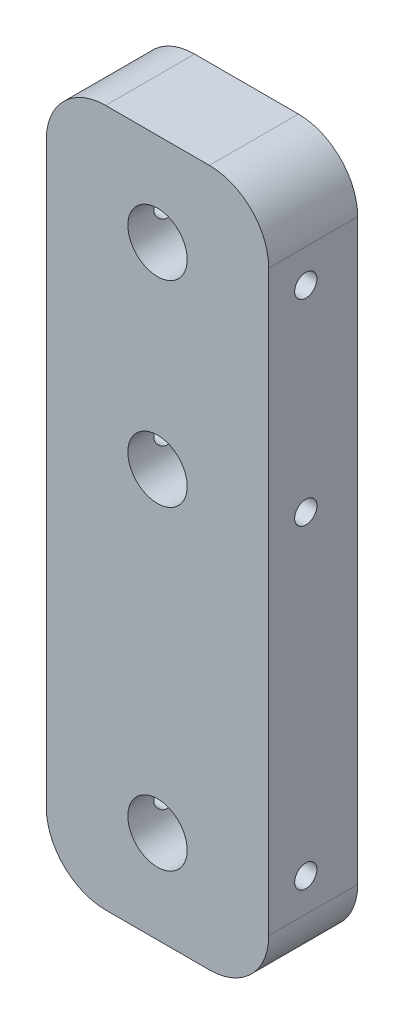
from build123d import *

# Parameters (mm, degrees)
SKETCH1_W           = 30
SKETCH1_H           = 93.98
BOSS_EXTRUDE1_DEPTH = 12
FILLET1_R           = 8
SKETCH2_R           = 4
CUT_EXTRUDE1_DEPTH  = 8
SKETCH3_R           = 1.5
CUT_EXTRUDE2_DEPTH  = 31
SKETCH4_R           = 2
CUT_EXTRUDE3_DEPTH  = 2.5


with BuildPart() as part:
    # Sketch1 → Boss-Extrude1 (new body)
    with BuildSketch(Plane.XY):
        Rectangle(SKETCH1_W, SKETCH1_H)
    extrude(amount=BOSS_EXTRUDE1_DEPTH)

    # Fillet1
    fillet1_edges = [part.edges().sort_by_distance(p)[0] for p in [
        (15, -46.99, 6),
        (-15, -46.99, 6),
        (-15, 46.99, 6),
        (15, 46.99, 6),
    ]]
    fillet(fillet1_edges, radius=FILLET1_R)

    # Sketch2 → Cut-Extrude1 (cut)
    with BuildSketch(Plane.XY.offset(12)):
        with Locations((0, 7.99)):
            Circle(SKETCH2_R)
        with Locations((0, 34.49)):
            Circle(SKETCH2_R)
        with Locations((0, -34.494880812)):
            Circle(SKETCH2_R)
    extrude(amount=-CUT_EXTRUDE1_DEPTH, mode=Mode.SUBTRACT)

    # Sketch3 → Cut-Extrude2 (cut, through all)
    with BuildSketch(Plane.ZY.offset(15)):
        with Locations((7, 34.49)):
            Circle(SKETCH3_R)
        with Locations((7, 7.99)):
            Circle(SKETCH3_R)
        with Locations((7, -34.494880812)):
            Circle(SKETCH3_R)
    extrude(amount=-CUT_EXTRUDE2_DEPTH, mode=Mode.SUBTRACT)

    # Sketch4 → Cut-Extrude3 (cut)
    with BuildSketch(Plane(origin=(0, 0, 0), x_dir=(-1, 0, 0), z_dir=(0, 0, -1))):
        with Locations((0, -26.99)):
            Circle(SKETCH4_R)
        with Locations((0, 26.99)):
            Circle(SKETCH4_R)
    extrude(amount=-CUT_EXTRUDE3_DEPTH, mode=Mode.SUBTRACT)


solid = part.part
